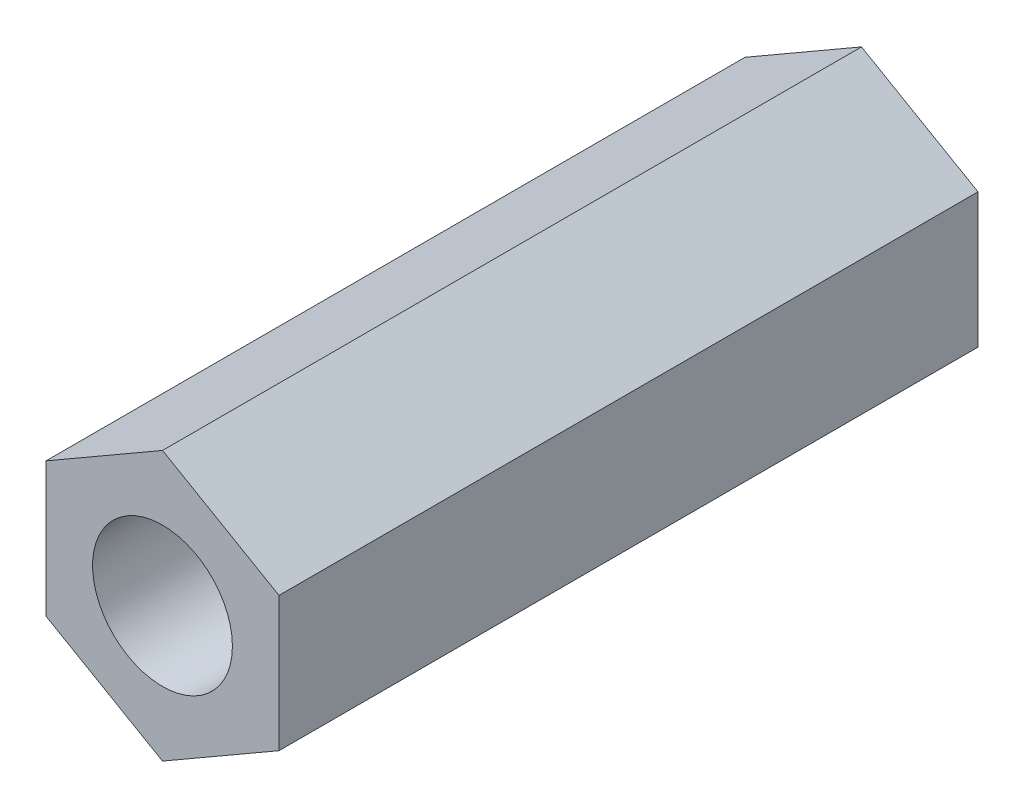
from build123d import *

# Parameters (mm, degrees)
SKETCH_1_R      = 1.5
EXTRUDE_1_DEPTH = 15


with BuildPart() as part:
    # 草图1 → 凸台-拉伸1 (new body)
    with BuildSketch(Plane.XY):
        Polygon((2.5, 1.443375673), (0, 2.886751346), (-2.5, 1.443375673), (-2.5, -1.443375673), (0, -2.886751346), (2.5, -1.443375673), align=None)
        Circle(SKETCH_1_R, mode=Mode.SUBTRACT)
    extrude(amount=EXTRUDE_1_DEPTH)


solid = part.part
